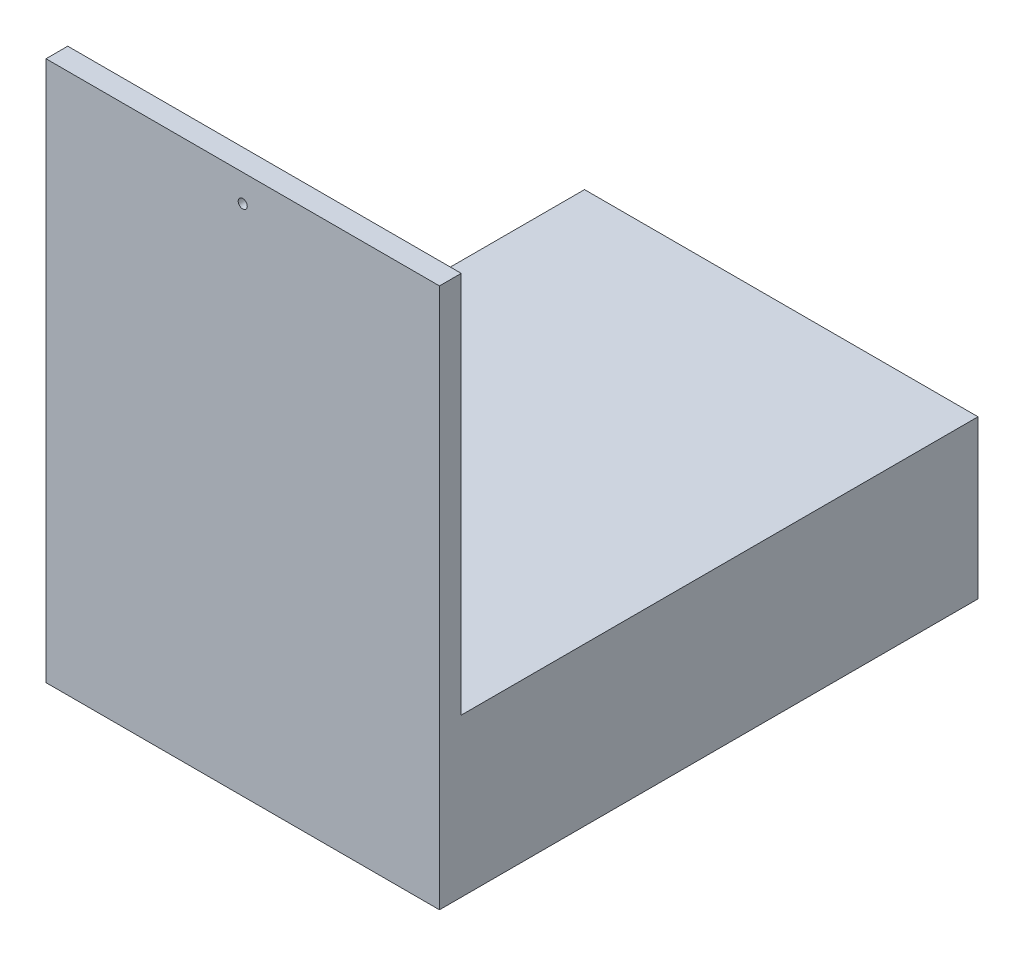
from build123d import *

# Parameters (mm, degrees)
BOSS_EXTRUDE1_DEPTH = 12
SKETCH2_R           = 2.5
CUT_EXTRUDE1_DEPTH  = 13
SKETCH3_W           = 217
SKETCH3_H           = 87
BOSS_EXTRUDE2_DEPTH = 285


with BuildPart() as part:
    # Sketch1 → Boss-Extrude1 (new body)
    with BuildSketch(Plane.XY):
        Polygon((-108.5, 149), (108.5, 149), (108.5, -107), (108.5, -149), (-108.5, -149), (-108.5, -107), align=None)
    extrude(amount=BOSS_EXTRUDE1_DEPTH)

    # Sketch2 → Cut-Extrude1 (cut, through all)
    with BuildSketch(Plane(origin=(0, 0, 0), x_dir=(-1, 0, 0), z_dir=(0, 0, -1))):
        with Locations((0, 134)):
            Circle(SKETCH2_R)
    extrude(amount=-CUT_EXTRUDE1_DEPTH, mode=Mode.SUBTRACT)

    # Sketch3 → Boss-Extrude2 (add)
    with BuildSketch(Plane(origin=(0, 0, 0), x_dir=(-1, 0, 0), z_dir=(0, 0, -1))):
        with Locations((0, -105.5)):
            Rectangle(SKETCH3_W, SKETCH3_H)
    extrude(amount=BOSS_EXTRUDE2_DEPTH)


solid = part.part
